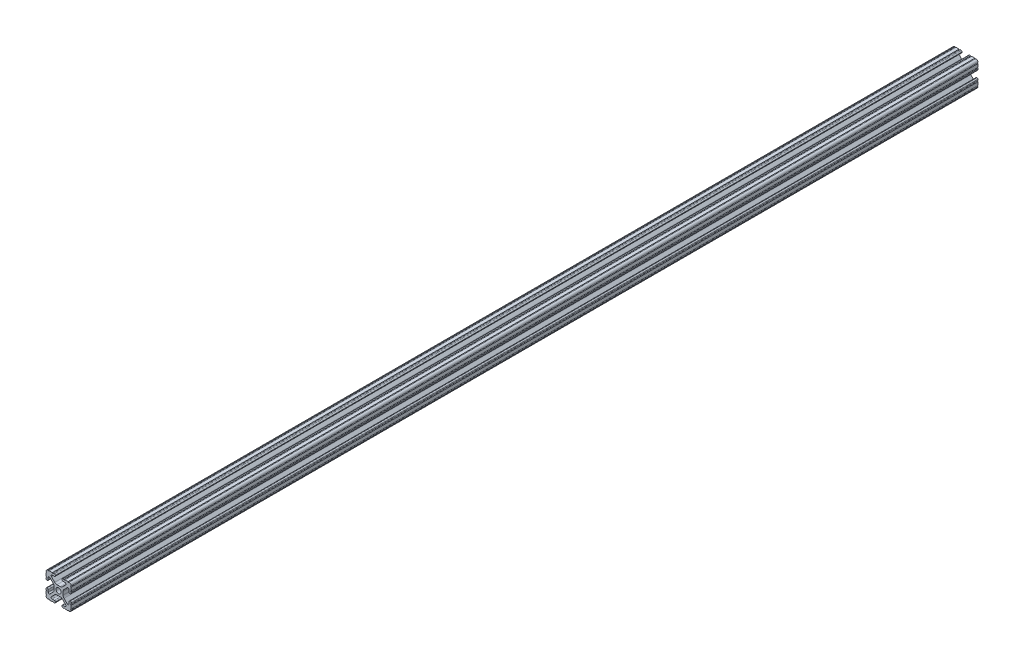
from build123d import *

# Parameters (mm, degrees)
SKETCH1_R           = 2.6035
BOSS_EXTRUDE1_DEPTH = 457.2


with BuildPart() as part:
    # Sketch1 → Boss-Extrude1 (new body, symmetric)
    with BuildSketch(Plane.XY):
        with BuildLine():
            Line((-7.179650497, -8.645192506), (-3.952270251, -5.423690499))
            ThreePointArc((-3.952270251, -5.423690499), (-2.922936451, -4.736929036), (-1.709253557, -4.4958))
            Line((-1.709253557, -4.4958), (1.709253557, -4.4958))
            ThreePointArc((1.709253557, -4.4958), (2.922936451, -4.736929036), (3.952270251, -5.423690499))
            Line((3.952270251, -5.423690499), (7.179650497, -8.645192506))
            ThreePointArc((7.179650497, -8.645192506), (7.41473083, -9.822813117), (6.416408329, -10.4902))
            Line((6.416408329, -10.4902), (4.287512407, -10.4902))
            ThreePointArc((4.287512407, -10.4902), (3.54574862, -10.79744862), (3.2385, -11.539212407))
            Line((3.2385, -11.539212407), (3.2385, -11.650987593))
            ThreePointArc((3.2385, -11.650987593), (3.54574862, -12.39275138), (4.287512407, -12.7))
            Line((4.287512407, -12.7), (5.317126718, -12.7))
            ThreePointArc((5.317126718, -12.7), (5.825126718, -12.192), (6.333126718, -12.7))
            Line((6.333126718, -12.7), (9.550443118, -12.7))
            ThreePointArc((9.550443118, -12.7), (10.058366869, -12.192000006), (10.566443095, -12.699847501))
            ThreePointArc((10.566443095, -12.699847501), (12.082537762, -12.08250727), (12.699846982, -10.566399977))
            ThreePointArc((12.699846982, -10.566399977), (12.192000006, -10.058323491), (12.7, -9.5504))
            Line((12.7, -9.5504), (12.7, -6.3330836))
            ThreePointArc((12.7, -6.3330836), (12.192, -5.8250836), (12.7, -5.3170836))
            Line((12.7, -5.3170836), (12.7, -4.287469289))
            ThreePointArc((12.7, -4.287469289), (12.39275138, -3.545705502), (11.650987593, -3.238456882))
            Line((11.650987593, -3.238456882), (11.539212407, -3.238456882))
            ThreePointArc((11.539212407, -3.238456882), (10.79744862, -3.545705502), (10.4902, -4.287469289))
            Line((10.4902, -4.287469289), (10.4902, -6.402089023))
            ThreePointArc((10.4902, -6.402089023), (9.856505071, -7.351067942), (8.737131347, -7.129408934))
            Line((8.737131347, -7.129408934), (5.441005833, -3.840816462))
            ThreePointArc((5.441005833, -3.840816462), (4.750877967, -2.809883091), (4.5085, -1.593185507))
            Line((4.5085, -1.593185507), (4.5085, 1.593185507))
            ThreePointArc((4.5085, 1.593185507), (4.750877967, 2.809883091), (5.441005833, 3.840816462))
            Line((5.441005833, 3.840816462), (8.737131347, 7.129408934))
            ThreePointArc((8.737131347, 7.129408934), (9.856505071, 7.351067942), (10.4902, 6.402089023))
            Line((10.4902, 6.402089023), (10.4902, 4.287469289))
            ThreePointArc((10.4902, 4.287469289), (10.79744862, 3.545705502), (11.539212407, 3.238456882))
            Line((11.539212407, 3.238456882), (11.650987593, 3.238456882))
            ThreePointArc((11.650987593, 3.238456882), (12.39275138, 3.545705502), (12.7, 4.287469289))
            Line((12.7, 4.287469289), (12.7, 5.3170836))
            ThreePointArc((12.7, 5.3170836), (12.192, 5.8250836), (12.7, 6.3330836))
            Line((12.7, 6.3330836), (12.7, 9.5504))
            ThreePointArc((12.7, 9.5504), (12.192000006, 10.058323491), (12.699846982, 10.566399977))
            ThreePointArc((12.699846982, 10.566399977), (12.082537762, 12.08250727), (10.566443095, 12.699847501))
            ThreePointArc((10.566443095, 12.699847501), (10.058366869, 12.192000006), (9.550443118, 12.7))
            Line((9.550443118, 12.7), (6.333126718, 12.7))
            ThreePointArc((6.333126718, 12.7), (5.825126718, 12.192), (5.317126718, 12.7))
            Line((5.317126718, 12.7), (4.287512407, 12.7))
            ThreePointArc((4.287512407, 12.7), (3.54574862, 12.39275138), (3.2385, 11.650987593))
            Line((3.2385, 11.650987593), (3.2385, 11.539212407))
            ThreePointArc((3.2385, 11.539212407), (3.54574862, 10.79744862), (4.287512407, 10.4902))
            Line((4.287512407, 10.4902), (6.476788598, 10.4902))
            ThreePointArc((6.476788598, 10.4902), (7.432222385, 9.85140422), (7.207036008, 8.724370562))
            Line((7.207036008, 8.724370562), (3.898272566, 5.423169045))
            ThreePointArc((3.898272566, 5.423169045), (2.869120213, 4.736787962), (1.655778399, 4.4958))
            Line((1.655778399, 4.4958), (-1.655778399, 4.4958))
            ThreePointArc((-1.655778399, 4.4958), (-2.869120213, 4.736787962), (-3.898272566, 5.423169045))
            Line((-3.898272566, 5.423169045), (-7.207036008, 8.724370562))
            ThreePointArc((-7.207036008, 8.724370562), (-7.432222385, 9.85140422), (-6.476788598, 10.4902))
            Line((-6.476788598, 10.4902), (-4.287512407, 10.4902))
            ThreePointArc((-4.287512407, 10.4902), (-3.54574862, 10.79744862), (-3.2385, 11.539212407))
            Line((-3.2385, 11.539212407), (-3.2385, 11.650987593))
            ThreePointArc((-3.2385, 11.650987593), (-3.54574862, 12.39275138), (-4.287512407, 12.7))
            Line((-4.287512407, 12.7), (-5.317126718, 12.7))
            ThreePointArc((-5.317126718, 12.7), (-5.825126718, 12.192), (-6.333126718, 12.7))
            Line((-6.333126718, 12.7), (-9.550443118, 12.7))
            ThreePointArc((-9.550443118, 12.7), (-10.058366869, 12.192000006), (-10.566443095, 12.699847501))
            ThreePointArc((-10.566443095, 12.699847501), (-12.082537762, 12.08250727), (-12.699846982, 10.566399977))
            ThreePointArc((-12.699846982, 10.566399977), (-12.192000006, 10.058323491), (-12.7, 9.5504))
            Line((-12.7, 9.5504), (-12.7, 6.3330836))
            ThreePointArc((-12.7, 6.3330836), (-12.192, 5.8250836), (-12.7, 5.3170836))
            Line((-12.7, 5.3170836), (-12.7, 4.287469289))
            ThreePointArc((-12.7, 4.287469289), (-12.39275138, 3.545705502), (-11.650987593, 3.238456882))
            Line((-11.650987593, 3.238456882), (-11.539212407, 3.238456882))
            ThreePointArc((-11.539212407, 3.238456882), (-10.79744862, 3.545705502), (-10.4902, 4.287469289))
            Line((-10.4902, 4.287469289), (-10.4902, 6.402089023))
            ThreePointArc((-10.4902, 6.402089023), (-9.856505071, 7.351067942), (-8.737131347, 7.129408934))
            Line((-8.737131347, 7.129408934), (-5.441005833, 3.840816462))
            ThreePointArc((-5.441005833, 3.840816462), (-4.750877967, 2.809883091), (-4.5085, 1.593185507))
            Line((-4.5085, 1.593185507), (-4.5085, -1.593185507))
            ThreePointArc((-4.5085, -1.593185507), (-4.750877967, -2.809883091), (-5.441005833, -3.840816462))
            Line((-5.441005833, -3.840816462), (-8.737131347, -7.129408934))
            ThreePointArc((-8.737131347, -7.129408934), (-9.856505071, -7.351067942), (-10.4902, -6.402089023))
            Line((-10.4902, -6.402089023), (-10.4902, -4.287469289))
            ThreePointArc((-10.4902, -4.287469289), (-10.79744862, -3.545705502), (-11.539212407, -3.238456882))
            Line((-11.539212407, -3.238456882), (-11.650987593, -3.238456882))
            ThreePointArc((-11.650987593, -3.238456882), (-12.39275138, -3.545705502), (-12.7, -4.287469289))
            Line((-12.7, -4.287469289), (-12.7, -5.3170836))
            ThreePointArc((-12.7, -5.3170836), (-12.192, -5.8250836), (-12.7, -6.3330836))
            Line((-12.7, -6.3330836), (-12.7, -9.5504))
            ThreePointArc((-12.7, -9.5504), (-12.192000006, -10.058323491), (-12.699846982, -10.566399977))
            ThreePointArc((-12.699846982, -10.566399977), (-12.082537762, -12.08250727), (-10.566443095, -12.699847501))
            ThreePointArc((-10.566443095, -12.699847501), (-10.058366869, -12.192000006), (-9.550443118, -12.7))
            Line((-9.550443118, -12.7), (-6.333126718, -12.7))
            ThreePointArc((-6.333126718, -12.7), (-5.825126718, -12.192), (-5.317126718, -12.7))
            Line((-5.317126718, -12.7), (-4.287512407, -12.7))
            ThreePointArc((-4.287512407, -12.7), (-3.54574862, -12.39275138), (-3.2385, -11.650987593))
            Line((-3.2385, -11.650987593), (-3.2385, -11.539212407))
            ThreePointArc((-3.2385, -11.539212407), (-3.54574862, -10.79744862), (-4.287512407, -10.4902))
            Line((-4.287512407, -10.4902), (-6.416408329, -10.4902))
            ThreePointArc((-6.416408329, -10.4902), (-7.41473083, -9.822813117), (-7.179650497, -8.645192506))
        make_face()
        Circle(SKETCH1_R, mode=Mode.SUBTRACT)
    extrude(amount=BOSS_EXTRUDE1_DEPTH, both=True)


solid = part.part
